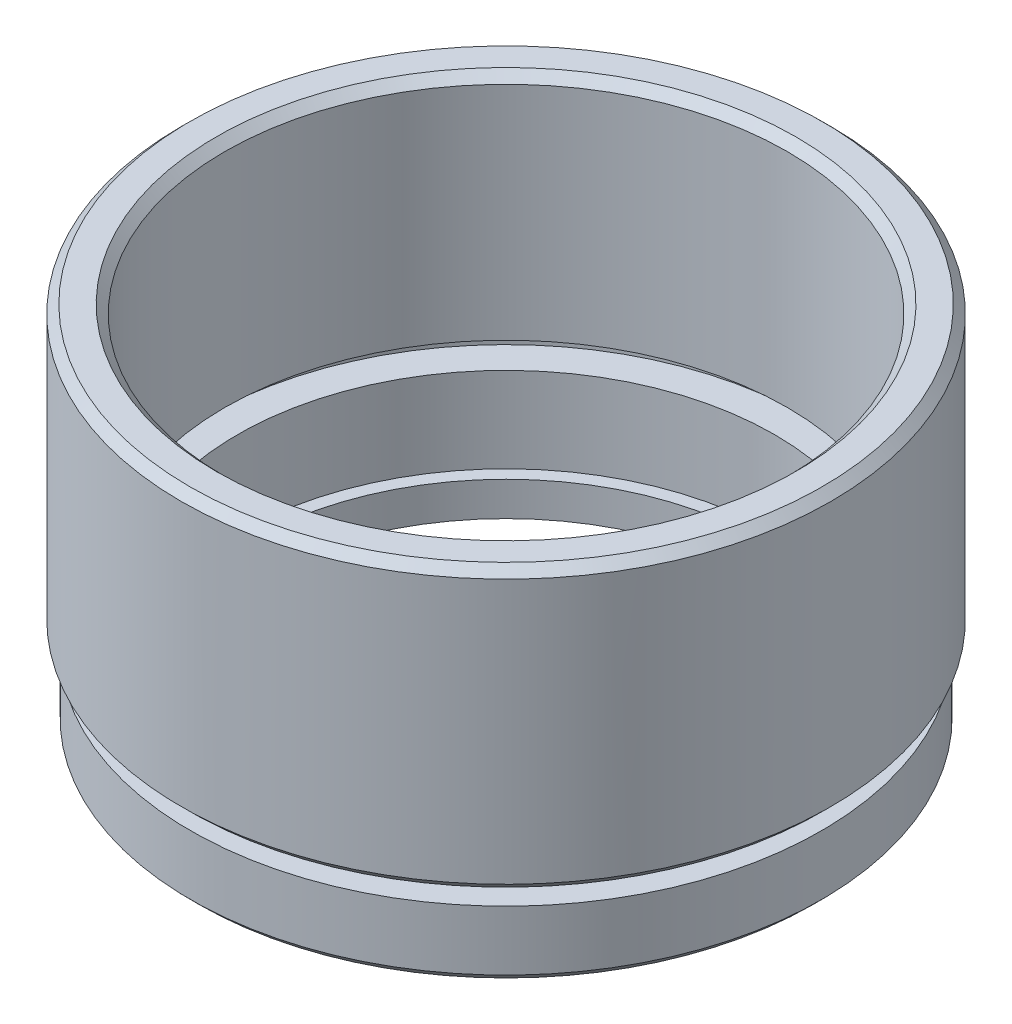
from build123d import *

# Parameters (mm, degrees)
CHAMFER_1_SIZE = 0.5


with BuildPart() as part:
    # 草图1 → 旋转1 (revolve)
    with BuildSketch(Plane.XY, mode=Mode.PRIVATE) as revolve_1_sk:
        Polygon((15, 0), (18.5, 0), (18.5, 4), (17, 4), (17, 5), (19.05, 5), (19.05, 21.5), (16.5, 21.5), (16.5, 8), (17.6, 8), (17.6, 7), (15.75, 7), (15.75, 2), (15, 2), align=None)
    revolve(revolve_1_sk.sketch.rotate(Axis((0, 0, 0), (0, 1, 0)), 90), axis=Axis((0, 0, 0), (0, 1, 0)))  # turned: the seam where the file's is

    # 倒角1
    chamfer_1_edges = [part.edges().sort_by_distance(p)[0] for p in [
        (0, 21.5, 16.5),
        (0, 21.5, 19.05),
        (0, 5, 19.05),
        (0, 0, 18.5),
    ]]
    chamfer(chamfer_1_edges, length=CHAMFER_1_SIZE)


solid = part.part
